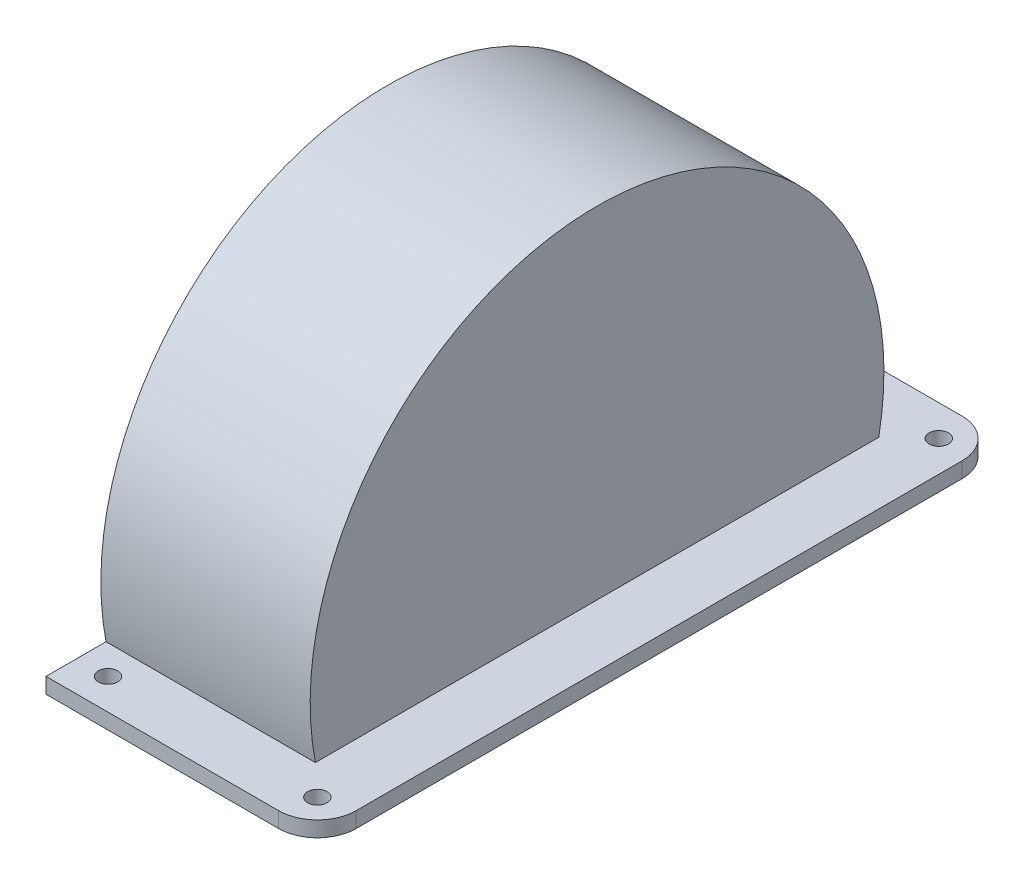
from build123d import *

# Parameters (mm, degrees)
BOSS_EXTRUDE1_DEPTH = 14.5
SHELL1_T            = -2
SKETCH3_R           = 1.25
SKETCH3_W           = 25
SKETCH3_H           = 68.14690015
BOSS_EXTRUDE2_DEPTH = 1
CUT_EXTRUDE1_DEPTH  = 2


with BuildPart() as part:
    # Sketch1 → Boss-Extrude1 (new body, symmetric)
    with BuildSketch(Plane(origin=(0, 0, 0), x_dir=(0, 0, -1), z_dir=(1, 0, 0))):
        with BuildLine():
            Line((-36.124783736, -8), (36.124783736, -8))
            ThreePointArc((36.124783736, -8), (0, 37), (-36.124783736, -8))
        make_face()
    extrude(amount=BOSS_EXTRUDE1_DEPTH, both=True)

    # Shell1
    shell1_openings = [part.faces().sort_by_distance(p)[0] for p in [
        (0, -8, 0),
    ]]
    offset(amount=SHELL1_T, openings=shell1_openings)

    # Sketch3 → Boss-Extrude2 (add, symmetric)
    with BuildSketch(Plane.XZ.offset(8)):
        with BuildLine():
            Line((-9.5, 44.073450075), (17.5, 44.073450075))
            ThreePointArc((17.5, 44.073450075), (21.035533906, 42.608983981), (22.5, 39.073450075))
            Line((22.5, 39.073450075), (22.5, -39.073450075))
            ThreePointArc((22.5, -39.073450075), (21.035533906, -42.608983981), (17.5, -44.073450075))
            Line((17.5, -44.073450075), (-9.5, -44.073450075))
            Line((-9.5, -44.073450075), (-14.5, -44.073450075))
            Line((-14.5, -44.073450075), (-14.5, -39.073450075))
            Line((-14.5, -39.073450075), (-14.5, 39.073450075))
            Line((-14.5, 39.073450075), (-14.5, 44.073450075))
            Line((-14.5, 44.073450075), (-9.5, 44.073450075))
        make_face()
        with Locations((18.5, 40.073450075)):
            Circle(SKETCH3_R, mode=Mode.SUBTRACT)
        with Locations((-8.5, 40.073450075)):
            Circle(SKETCH3_R, mode=Mode.SUBTRACT)
        with Locations((18.5, -40.073450075)):
            Circle(SKETCH3_R, mode=Mode.SUBTRACT)
        with Locations((-8.5, -40.073450075)):
            Circle(SKETCH3_R, mode=Mode.SUBTRACT)
        Rectangle(SKETCH3_W, SKETCH3_H, mode=Mode.SUBTRACT)
    extrude(amount=BOSS_EXTRUDE2_DEPTH, both=True)

    # Sketch4 → Cut-Extrude1 (cut)
    with BuildSketch(Plane(origin=(-12.5, 0, 0), x_dir=(0, 0, -1), z_dir=(1, 0, 0))):
        with BuildLine():
            Line((-44.073450075, -7), (-36.331804249, -7))
            ThreePointArc((-36.331804249, -7), (0, 37), (36.331804249, -7))
            Line((36.331804249, -7), (44.073450075, -7))
            Line((44.073450075, -7), (44.073450075, -9))
            Line((44.073450075, -9), (-44.073450075, -9))
            Line((-44.073450075, -9), (-44.073450075, -7))
        make_face()
    extrude(amount=-CUT_EXTRUDE1_DEPTH, mode=Mode.SUBTRACT)


solid = part.part
